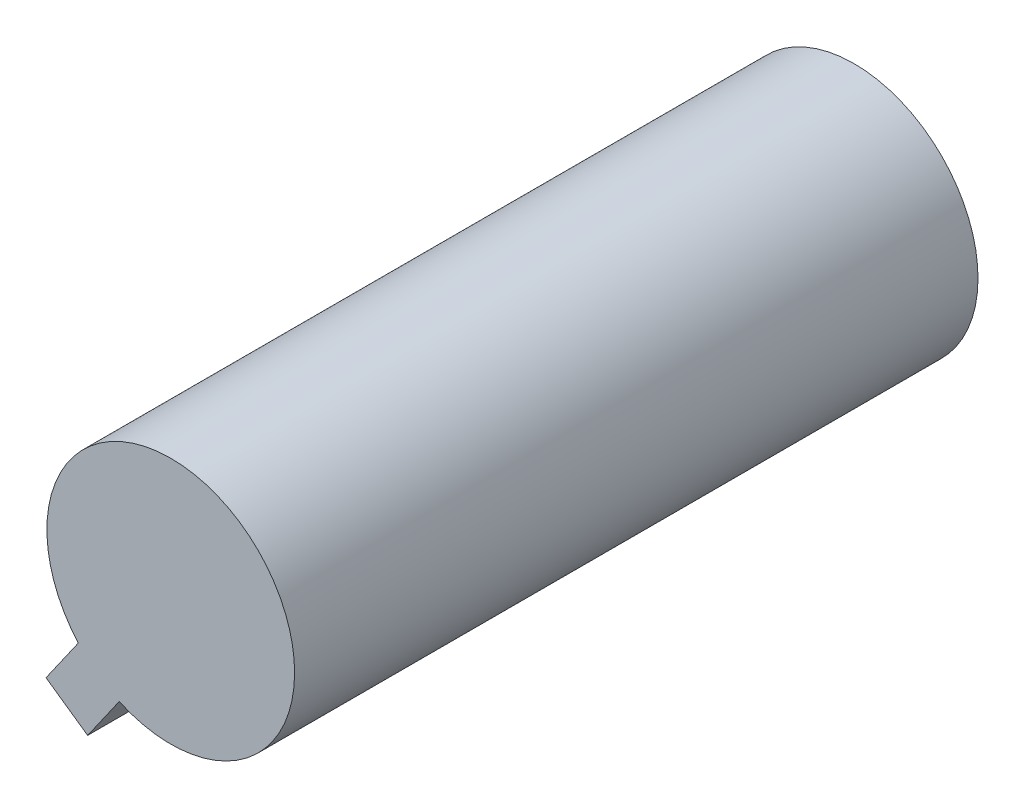
from build123d import *

# Parameters (mm, degrees)
SKETCH1_R             = 7
BOSS_EXTRUDE1_DEPTH   = 38.63
SKETCH2_W             = 2.872896842
SKETCH2_H             = 13.203310437
BOSS_EXTRUDE2_DEPTH   = 3
SKETCH2_H_2           = 13.668710778
BOSS_EXTRUDE2_2_DEPTH = 3
SKETCH3_W             = 2.872896842
SKETCH3_H             = 13.668710778
SKETCH3_H_2           = 13.203310437
BOSS_EXTRUDE3_DEPTH   = 10


with BuildPart() as part:
    # Sketch1 → Boss-Extrude1 (new body)
    with BuildSketch(Plane.XY):
        Circle(SKETCH1_R)
    extrude(amount=BOSS_EXTRUDE1_DEPTH)



with BuildPart() as body_2:
    # Sketch2 → Boss-Extrude2 (new body)
    with BuildSketch(Plane(origin=(-4.013864175, -5.73488399, 0), x_dir=(-0.819269141, 0.573409168, 0), z_dir=(-0.573409168, -0.819269141, 0))):
        with Locations((0.171883624, -6.601655219)):
            Rectangle(SKETCH2_W, SKETCH2_H)
    extrude(amount=BOSS_EXTRUDE2_DEPTH)


with BuildPart() as body_3:
    # Sketch2 → Boss-Extrude2 2 (new body)
    with BuildSketch(Plane(origin=(-4.013864175, -5.73488399, 0), x_dir=(-0.819269141, 0.573409168, 0), z_dir=(-0.573409168, -0.819269141, 0))):
        with Locations((0.171883624, -31.795644611)):
            Rectangle(SKETCH2_W, SKETCH2_H_2)
    extrude(amount=BOSS_EXTRUDE2_2_DEPTH)


with BuildPart() as part_1:
    add(part.part)

    add(body_2.part)  # Boss-Extrude3 merges body 2

    add(body_3.part)  # Boss-Extrude3 merges body 3
    # Sketch3 → Boss-Extrude3 (add)
    with BuildSketch(Plane(origin=(-4.013864175, -5.73488399, 0), x_dir=(0.819269141, -0.573409168, 0), z_dir=(0.573409168, 0.819269141, 0))):
        with Locations((-0.171883624, -31.795644611)):
            Rectangle(SKETCH3_W, SKETCH3_H)
        with Locations((-0.171883624, -6.601655219)):
            Rectangle(SKETCH3_W, SKETCH3_H_2)
    extrude(amount=BOSS_EXTRUDE3_DEPTH)


solid = part_1.part
